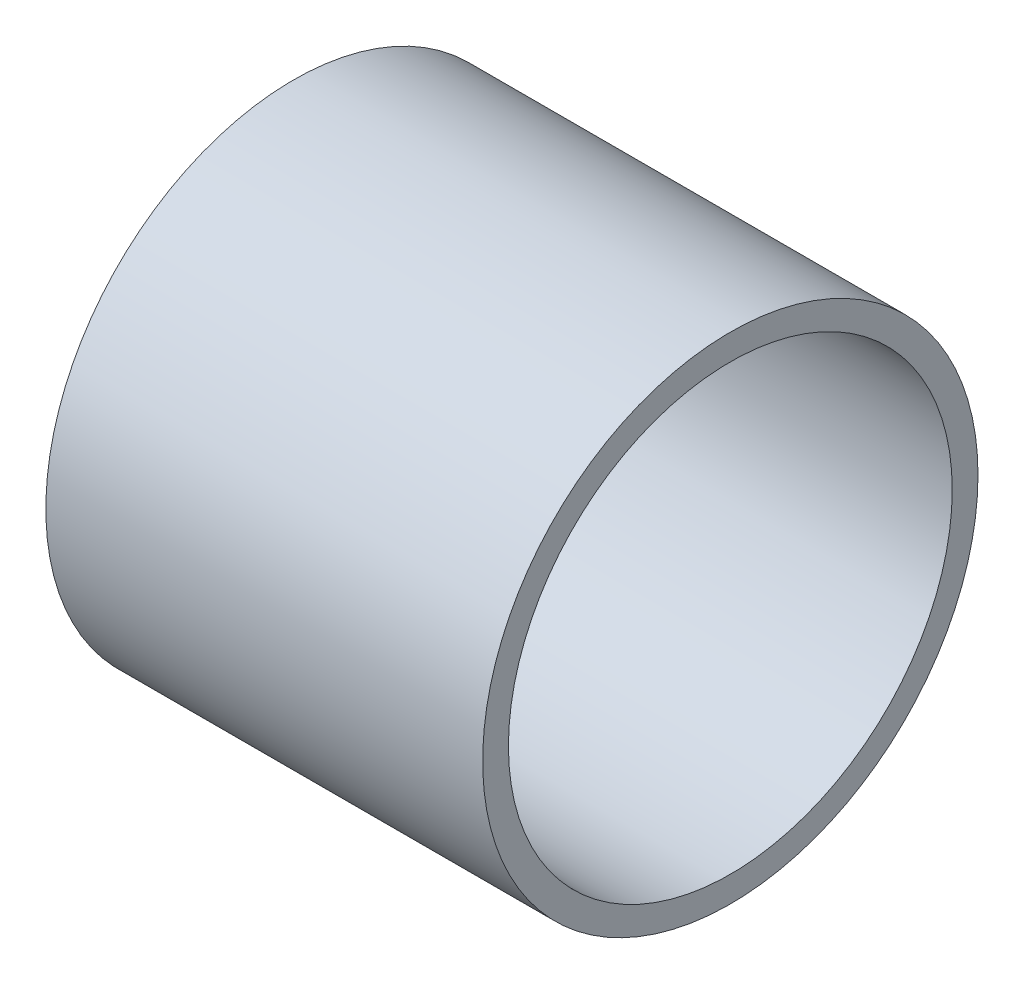
from build123d import *

# Parameters (mm, degrees)
SKETCH1_R           = 15.875
SKETCH1_R_2         = 14.224
BOSS_EXTRUDE1_DEPTH = 28


with BuildPart() as part:
    # Sketch1 → Boss-Extrude1 (new body)
    with BuildSketch(Plane(origin=(0, 0, 0), x_dir=(0, 0, -1), z_dir=(1, 0, 0))):
        Circle(SKETCH1_R)
        Circle(SKETCH1_R_2, mode=Mode.SUBTRACT)
    extrude(amount=BOSS_EXTRUDE1_DEPTH)


solid = part.part
